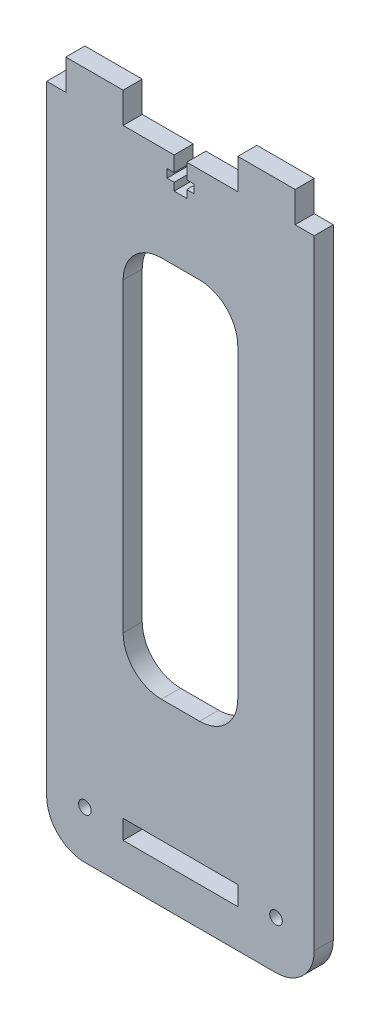
from build123d import *

# Parameters (mm, degrees)
SKETCH1_R           = 1.65
SKETCH1_W           = 30
SKETCH1_H           = 5
BOSS_EXTRUDE1_DEPTH = 5
CUT_EXTRUDE1_DEPTH  = 6
FILLET1_R           = 10


with BuildPart() as part:
    # Sketch1 → Boss-Extrude1 (new body)
    with BuildSketch(Plane.XY):
        Polygon((-52.5, 172), (-22.5, 172), (-22.5, 180), (-7.5, 180), (-7.5, 172), (-2.5, 172), (-2.5, 0), (-72.5, 0), (-72.5, 172), (-67.5, 172), (-67.5, 180), (-52.5, 180), align=None)
        with Locations((-62.5, 12.5)):
            Circle(SKETCH1_R, mode=Mode.SUBTRACT)
        with Locations((-12.5, 12.5)):
            Circle(SKETCH1_R, mode=Mode.SUBTRACT)
        with Locations((-37.5, 12.5)):
            Rectangle(SKETCH1_W, SKETCH1_H, mode=Mode.SUBTRACT)
        with BuildLine():
            Line((-32.5, 147), (-42.5, 147))
            ThreePointArc((-42.5, 147), (-49.571067812, 144.071067812), (-52.5, 137))
            Line((-52.5, 137), (-52.5, 57))
            ThreePointArc((-52.5, 57), (-49.571067812, 49.928932188), (-42.5, 47))
            Line((-42.5, 47), (-32.5, 47))
            ThreePointArc((-32.5, 47), (-25.428932188, 49.928932188), (-22.5, 57))
            Line((-22.5, 57), (-22.5, 137))
            ThreePointArc((-22.5, 137), (-25.428932188, 144.071067812), (-32.5, 147))
        make_face(mode=Mode.SUBTRACT)
    extrude(amount=BOSS_EXTRUDE1_DEPTH)

    # Sketch2 → Cut-Extrude1 (cut, through all)
    with BuildSketch(Plane.XY.offset(5)):
        Polygon((-35.85, 172), (-35.85, 168), (-34, 168), (-34, 165.8), (-35.85, 165.8), (-35.85, 163.8), (-39.15, 163.8), (-39.15, 165.8), (-41, 165.8), (-41, 168), (-39.15, 168), (-39.15, 172), align=None)
    extrude(amount=-CUT_EXTRUDE1_DEPTH, mode=Mode.SUBTRACT)

    # Fillet1
    fillet1_edges = [part.edges().sort_by_distance(p)[0] for p in [
        (-2.5, 0, 2.5),
        (-72.5, 0, 2.5),
    ]]
    fillet(fillet1_edges, radius=FILLET1_R)


solid = part.part
